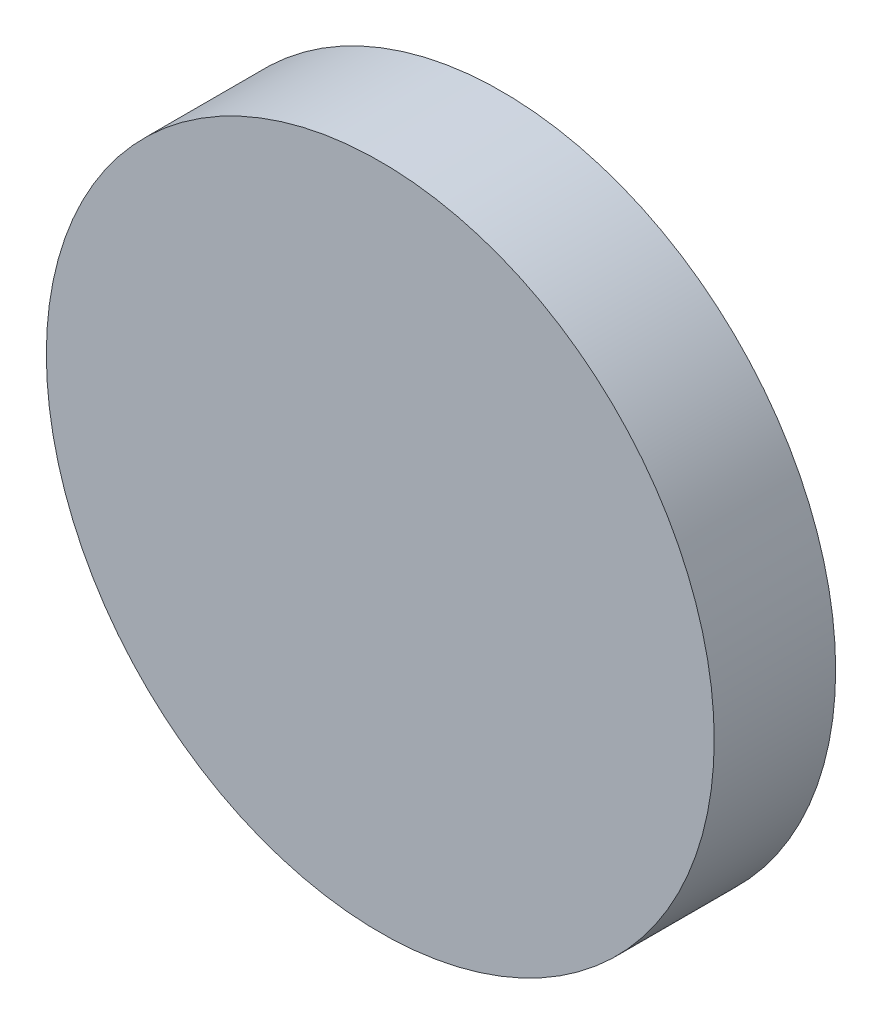
from build123d import *

# Parameters (mm, degrees)
SKETCH1_R           = 34.925
BOSS_EXTRUDE1_DEPTH = 12.7


with BuildPart() as part:
    # Sketch1 → Boss-Extrude1 (new body)
    with BuildSketch(Plane.XY):
        Circle(SKETCH1_R)
    extrude(amount=BOSS_EXTRUDE1_DEPTH)


solid = part.part
